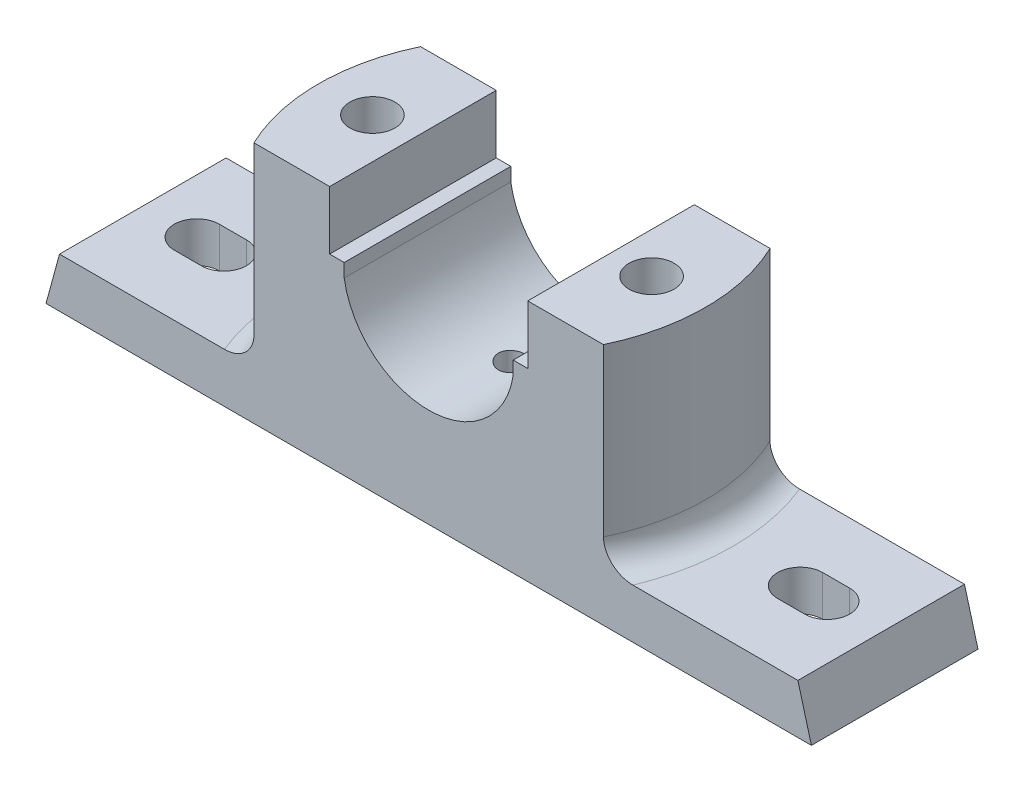
from build123d import *

# Parameters (mm, degrees)
BOSS_EXTRUDE1_DEPTH = 18.5
BOSS_EXTRUDE2_START = -11
BOSS_EXTRUDE2_DEPTH = 54
CUT_EXTRUDE1_DEPTH  = 27
SKETCH4_R           = 5
CUT_EXTRUDE2_DEPTH  = 55
SKETCH5_W           = 20
SKETCH5_H           = 20
CUT_EXTRUDE3_DEPTH  = 8
SKETCH6_W           = 71
SKETCH6_H           = 2
CUT_EXTRUDE4_DEPTH  = 11
CUT_EXTRUDE5_DEPTH  = 12
FILLET1_R           = 6


with BuildPart() as part:
    # Sketch1 → Boss-Extrude1 (new body, symmetric)
    with BuildSketch(Plane.XY):
        Polygon((-85, 0), (85, 0), (82, 11), (-82, 11), align=None)
    extrude(amount=BOSS_EXTRUDE1_DEPTH, both=True)

    # Sketch2 → Boss-Extrude2 (add)
    with BuildSketch(Plane(origin=(0, 11, 0), x_dir=(1, 0, 0), z_dir=(0, 1, 0)).offset(BOSS_EXTRUDE2_START)):
        with BuildLine():
            Line((38.816877772, -18.5), (-38.816877772, -18.5))
            ThreePointArc((-38.816877772, -18.5), (-43, 0), (-38.816877772, 18.5))
            Line((-38.816877772, 18.5), (38.816877772, 18.5))
            ThreePointArc((38.816877772, 18.5), (43, 0), (38.816877772, -18.5))
        make_face()
    extrude(amount=BOSS_EXTRUDE2_DEPTH)

    # Sketch3 → Cut-Extrude1 (cut, symmetric)
    with BuildSketch(Plane.XY):
        with BuildLine():
            Line((-22, 54), (-22, 41))
            Line((-22, 41), (-18.766334066, 41))
            Line((-18.766334066, 41), (-18.766334066, 38))
            ThreePointArc((-18.766334066, 38), (0, 21.970640627), (18.766334066, 38))
            Line((18.766334066, 38), (18.766334066, 41))
            Line((18.766334066, 41), (22, 41))
            Line((22, 41), (22, 54))
            Line((22, 54), (-22, 54))
        make_face()
    extrude(amount=CUT_EXTRUDE1_DEPTH, both=True, mode=Mode.SUBTRACT)

    # Sketch4 → Cut-Extrude2 (cut, through all)
    with BuildSketch(Plane(origin=(0, 54, 0), x_dir=(1, 0, 0), z_dir=(0, 1, 0))):
        with Locations((-31, 0)):
            Circle(SKETCH4_R)
        with Locations((31, 0)):
            Circle(SKETCH4_R)
    extrude(amount=-CUT_EXTRUDE2_DEPTH, mode=Mode.SUBTRACT)

    # Sketch5 → Cut-Extrude3 (cut)
    with BuildSketch(Plane.XZ):
        with Locations((-31, 0)):
            Rectangle(SKETCH5_W, SKETCH5_H)
        with Locations((31, 0)):
            Rectangle(SKETCH5_W, SKETCH5_H)
    extrude(amount=-CUT_EXTRUDE3_DEPTH, mode=Mode.SUBTRACT)

    # Sketch6 → Cut-Extrude4 (cut, symmetric)
    with BuildSketch(Plane.XY):
        with Locations((-39.5, 1)):
            Rectangle(SKETCH6_W, SKETCH6_H)
    cut_extrude4 = extrude(amount=CUT_EXTRUDE4_DEPTH, both=True, mode=Mode.SUBTRACT)

    # Mirror1: Cut-Extrude4 across plane
    add(cut_extrude4.mirror(Plane(origin=(0, 0, 0), x_dir=(0, 0, 1), z_dir=(1, 0, 0))), mode=Mode.SUBTRACT)

    # Sketch7 → Cut-Extrude5 (cut, through all)
    with BuildSketch(Plane(origin=(0, 11, 0), x_dir=(1, 0, 0), z_dir=(0, 1, 0))):
        with BuildLine():
            Line((-64, -5), (-70, -5))
            ThreePointArc((-70, -5), (-75, 0), (-70, 5))
            Line((-70, 5), (-64, 5))
            ThreePointArc((-64, 5), (-59, 0), (-64, -5))
        make_face()
        with BuildLine():
            Line((64, -5), (70, -5))
            ThreePointArc((70, -5), (75, 0), (70, 5))
            Line((70, 5), (64, 5))
            ThreePointArc((64, 5), (59, 0), (64, -5))
        make_face()
    extrude(amount=-CUT_EXTRUDE5_DEPTH, mode=Mode.SUBTRACT)

    # Sketch8 → Cut-Revolve1 (revolve, cut)
    with BuildSketch(Plane.XY):
        Polygon((0, 21.970640627), (0, 14.16805877), (3, 15.970640627), (3, 25.476225131), (0, 25.476225131), align=None)
    revolve(axis=Axis((0, 21.970640627, 0), (0, -1, 0)), mode=Mode.SUBTRACT)

    # Fillet1
    fillet1_edges = [part.edges().sort_by_distance(p)[0] for p in [
        (-43, 11, 0),
        (43, 11, 0),
    ]]
    fillet(fillet1_edges, radius=FILLET1_R)


solid = part.part
